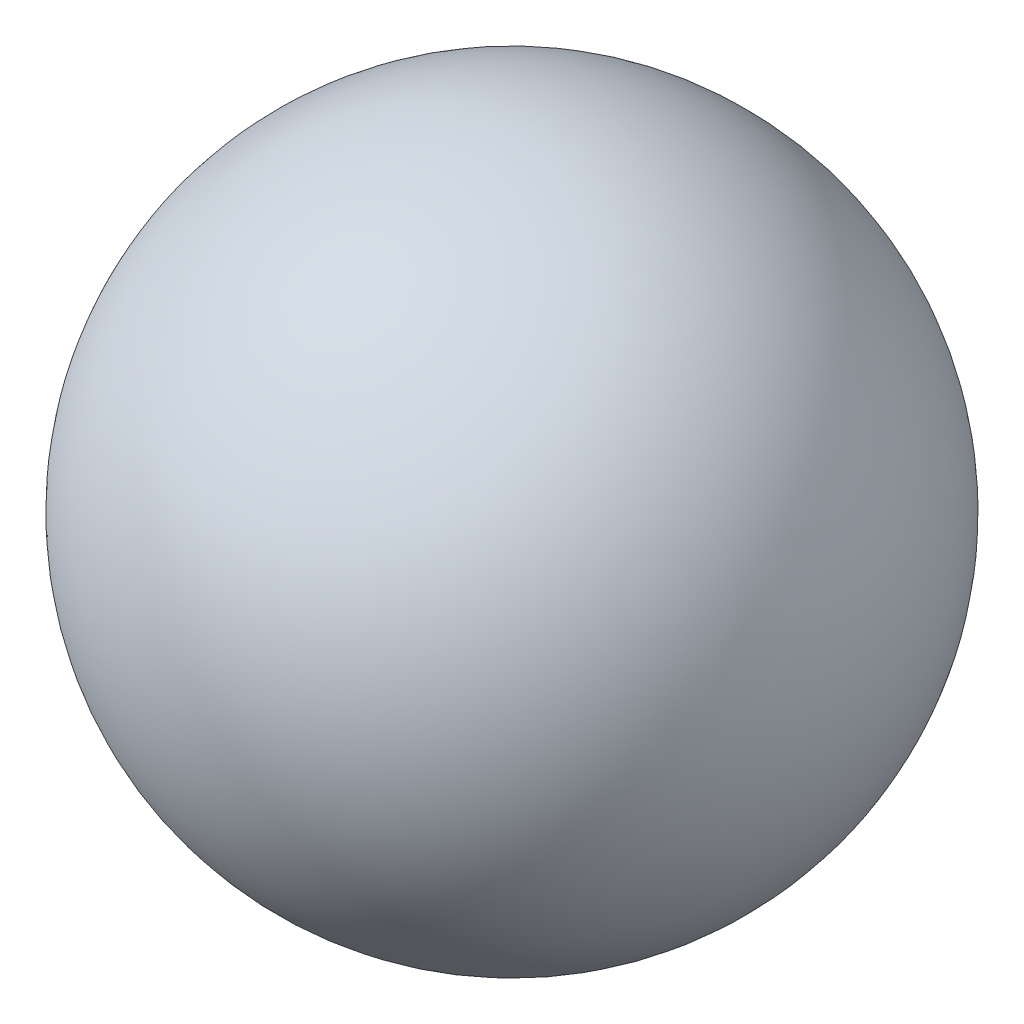
from build123d import *


with BuildPart() as part:
    # Sketch1 → Revolve1 (revolve)
    with BuildSketch(Plane(origin=(0, 0, 0), x_dir=(1, 0, 0), z_dir=(0, 1, 0))):
        with BuildLine():
            Line((0, 0), (-550, 0))
            ThreePointArc((-550, 0), (-275, 275), (0, 0))
        make_face()
    revolve(axis=Axis((0, 0, 0), (-1, 0, 0)))


solid = part.part
